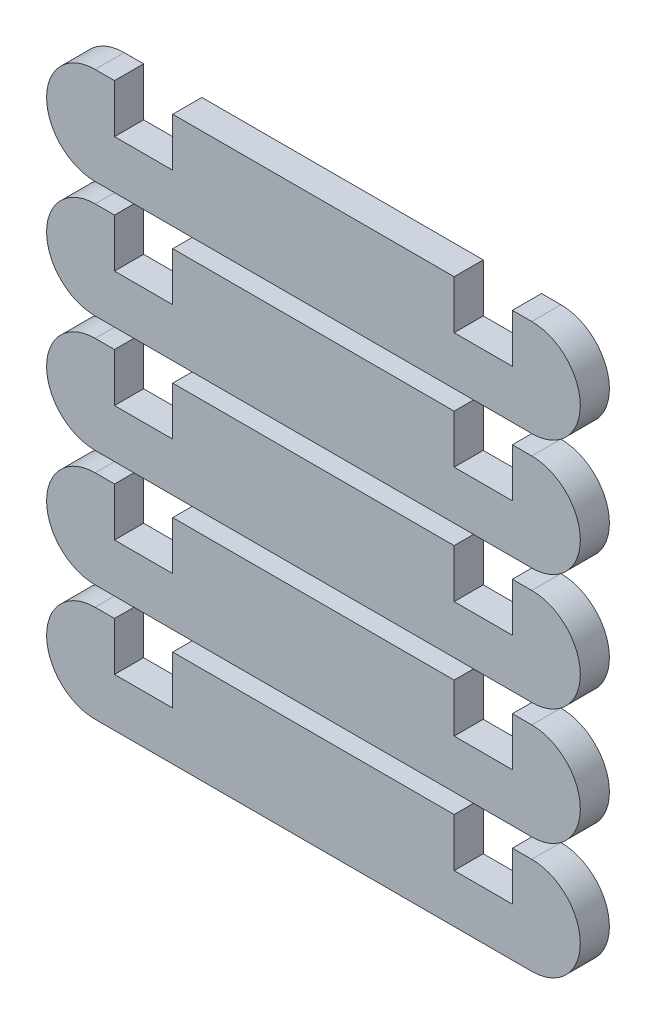
from build123d import *

# Parameters (mm, degrees)
BOSS_EXTRUDE4_DEPTH = 3
LPATTERN1_COUNT     = 5
LPATTERN1_PITCH     = 12


with BuildPart() as part:
    # Sketch2 → Boss-Extrude4 (new body)
    with BuildSketch(Plane.XY):
        with BuildLine():
            Line((-22.5, 5), (-20.5, 5))
            Line((-20.5, 5), (-20.5, 0))
            Line((-20.5, 0), (-14.5, 0))
            Line((-14.5, 0), (-14.5, 5))
            Line((-14.5, 5), (14.5, 5))
            Line((14.5, 5), (14.5, 0))
            Line((14.5, 0), (20.5, 0))
            Line((20.5, 0), (20.5, 5))
            Line((20.5, 5), (22.5, 5))
            ThreePointArc((22.5, 5), (27.5, 0), (22.5, -5))
            Line((22.5, -5), (-22.5, -5))
            ThreePointArc((-22.5, -5), (-27.5, 0), (-22.5, 5))
        make_face()
    extrude(amount=BOSS_EXTRUDE4_DEPTH)


with BuildPart() as lpattern1_1:
    # LPattern1: pattern copy
    add(part.part.moved(Location(Vector(0, 1, 0) * (1 * LPATTERN1_PITCH))))


with BuildPart() as lpattern1_2:
    # LPattern1: pattern copy
    add(part.part.moved(Location(Vector(0, 1, 0) * (2 * LPATTERN1_PITCH))))


with BuildPart() as lpattern1_3:
    # LPattern1: pattern copy
    add(part.part.moved(Location(Vector(0, 1, 0) * (3 * LPATTERN1_PITCH))))


with BuildPart() as lpattern1_4:
    # LPattern1: pattern copy
    add(part.part.moved(Location(Vector(0, 1, 0) * (4 * LPATTERN1_PITCH))))


solid = Compound([part.part, lpattern1_1.part, lpattern1_2.part, lpattern1_3.part, lpattern1_4.part])
